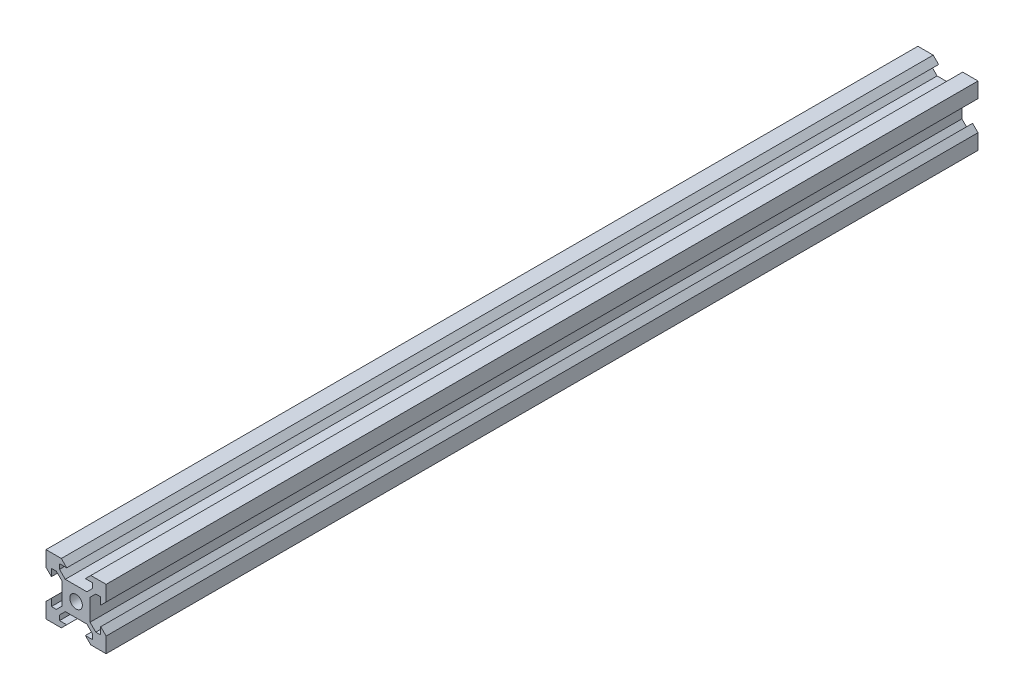
from build123d import *

# Parameters (mm, degrees)
SKETCH1_R           = 2.1
BOSS_EXTRUDE1_DEPTH = 145


with BuildPart() as part:
    # Sketch1 → Boss-Extrude1 (new body, symmetric)
    with BuildSketch(Plane.XY):
        Polygon((5.499339828, 6.56), (3.59, 4.650660172), (-3.59, 4.650660172), (-5.499339828, 6.56), (-5.499339828, 8.2), (-3.1, 8.2), (-4.9, 10), (-10, 10), (-10, 4.9), (-8.2, 3.1), (-8.2, 5.499339828), (-6.56, 5.499339828), (-4.650660172, 3.59), (-4.650660172, -3.59), (-6.56, -5.499339828), (-8.2, -5.499339828), (-8.2, -3.1), (-10, -4.9), (-10, -10), (-4.9, -10), (-3.1, -8.2), (-5.499339828, -8.2), (-5.499339828, -6.56), (-3.59, -4.650660172), (3.59, -4.650660172), (5.499339828, -6.56), (5.499339828, -8.2), (3.1, -8.2), (4.9, -10), (10, -10), (10, -4.9), (8.2, -3.1), (8.2, -5.499339828), (6.56, -5.499339828), (4.650660172, -3.59), (4.650660172, 3.59), (6.56, 5.499339828), (8.2, 5.499339828), (8.2, 3.1), (10, 4.9), (10, 10), (4.9, 10), (3.1, 8.2), (5.499339828, 8.2), align=None)
        Circle(SKETCH1_R, mode=Mode.SUBTRACT)
    extrude(amount=BOSS_EXTRUDE1_DEPTH, both=True)


solid = part.part
